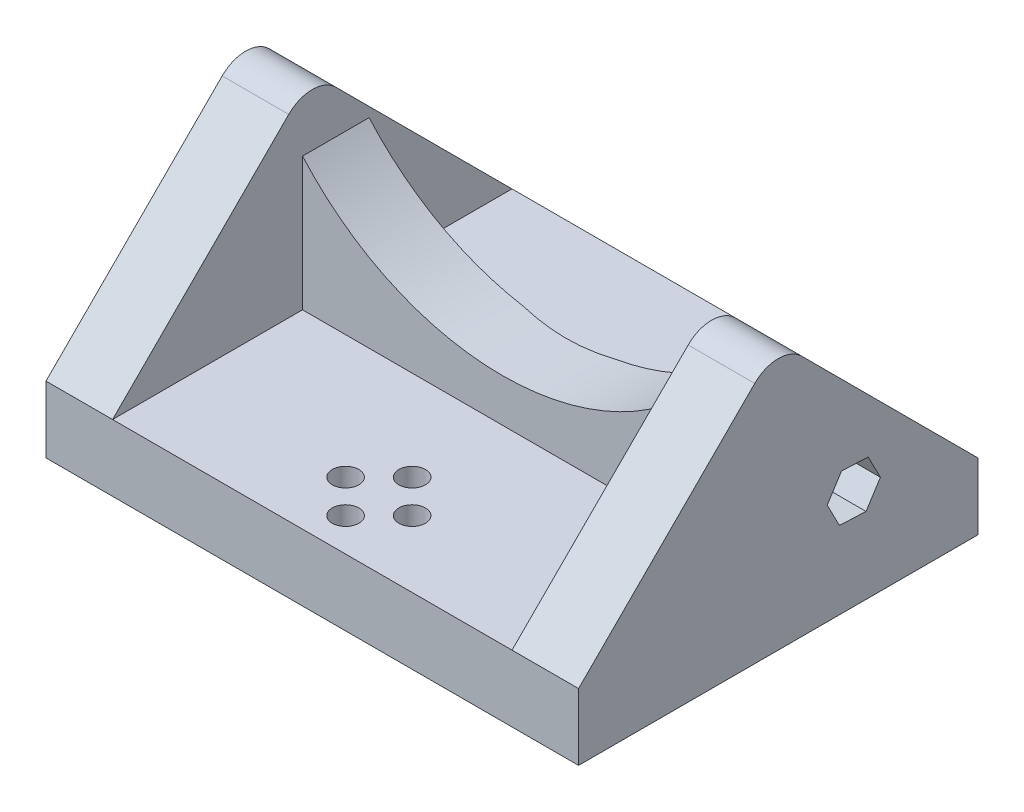
from build123d import *

# Parameters (mm, degrees)
SKETCH1_W           = 80
SKETCH1_H           = 60
BOSS_EXTRUDE1_DEPTH = 10
BOSS_EXTRUDE2_DEPTH = 10
LPATTERN2_COUNT     = 2
LPATTERN2_PITCH     = 70
FILLET1_R           = 5
BOSS_EXTRUDE3_START = -33.53553
BOSS_EXTRUDE3_DEPTH = 5
SKETCH4_R           = 2
CUT_EXTRUDE1_DEPTH  = 11
CUT_EXTRUDE2_DEPTH  = 81


with BuildPart() as part:
    # Sketch1 → Boss-Extrude1 (new body)
    with BuildSketch(Plane(origin=(0, 0, 0), x_dir=(1, 0, 0), z_dir=(0, 1, 0))):
        with Locations((-40, 30)):
            Rectangle(SKETCH1_W, SKETCH1_H)
    extrude(amount=BOSS_EXTRUDE1_DEPTH)

    # Sketch2 → Boss-Extrude2 (add)
    with BuildSketch(Plane(origin=(0, 0, 0), x_dir=(0, 0, -1), z_dir=(1, 0, 0))):
        Polygon((0, 10), (30, 40), (60, 10), align=None)
    boss_extrude2 = extrude(amount=-BOSS_EXTRUDE2_DEPTH)

    # LPattern2: Boss-Extrude2 ×2
    with Locations(*[(-i * LPATTERN2_PITCH, 0, 0) for i in range(1, LPATTERN2_COUNT)]):
        add(boss_extrude2)

    # Fillet1
    fillet1_edges = [part.edges().sort_by_distance(p)[0] for p in [
        (-5, 40, -30),
        (-75, 40, -30),
    ]]
    fillet(fillet1_edges, radius=FILLET1_R)

    # Sketch3 → Boss-Extrude3 (add, symmetric)
    with BuildSketch(Plane.XY.offset(BOSS_EXTRUDE3_START)):
        with BuildLine():
            Line((-70, 30), (-70, 10))
            Line((-70, 10), (-10, 10))
            Line((-10, 10), (-10, 30))
            ThreePointArc((-10, 30), (-40, 16.457513111), (-70, 30))
        make_face()
    extrude(amount=BOSS_EXTRUDE3_DEPTH, both=True)

    # Sketch4 → Cut-Extrude1 (cut, through all)
    with BuildSketch(Plane(origin=(0, 10, 0), x_dir=(1, 0, 0), z_dir=(0, 1, 0))):
        with Locations((-40, 15)):
            Circle(SKETCH4_R)
        with Locations((-35, 10)):
            Circle(SKETCH4_R)
        with Locations((-40, 5)):
            Circle(SKETCH4_R)
        with Locations((-45, 10)):
            Circle(SKETCH4_R)
    extrude(amount=-CUT_EXTRUDE1_DEPTH, mode=Mode.SUBTRACT)

    # Sketch5 → Cut-Extrude2 (cut, through all)
    with BuildSketch(Plane(origin=(0, 0, 0), x_dir=(0, 0, -1), z_dir=(1, 0, 0))):
        Polygon((43.184207347, 11.448981874), (45.338844925, 14.81907637), (43.497576267, 18.370094496), (39.501670032, 18.551018126), (37.347032454, 15.18092363), (39.188301112, 11.629905504), align=None)
    extrude(amount=-CUT_EXTRUDE2_DEPTH, mode=Mode.SUBTRACT)


solid = part.part
